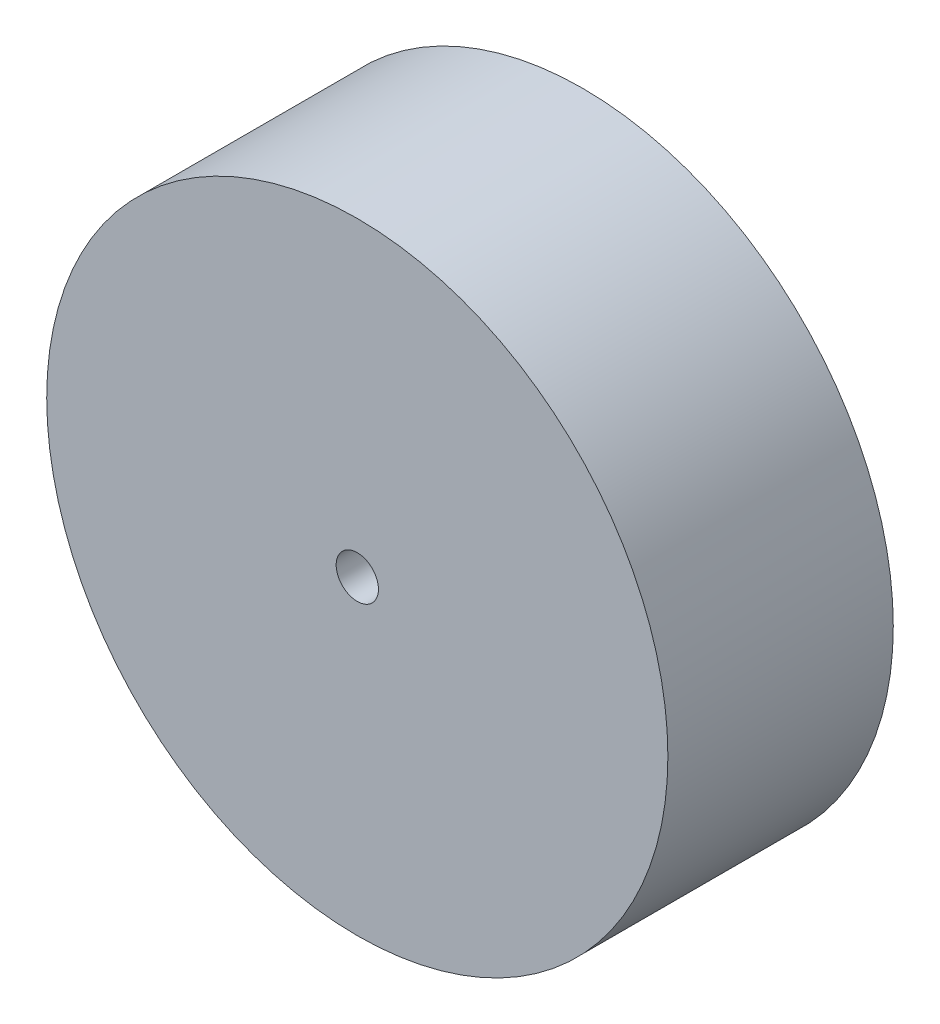
from build123d import *

# Parameters (mm, degrees)
SKETCH1_R           = 35.000057
SKETCH1_R_2         = 2.38125
BOSS_EXTRUDE1_DEPTH = 25.4


with BuildPart() as part:
    # Sketch1 → Boss-Extrude1 (new body)
    with BuildSketch(Plane.XY):
        Circle(SKETCH1_R)
        Circle(SKETCH1_R_2, mode=Mode.SUBTRACT)
    extrude(amount=BOSS_EXTRUDE1_DEPTH)


solid = part.part
